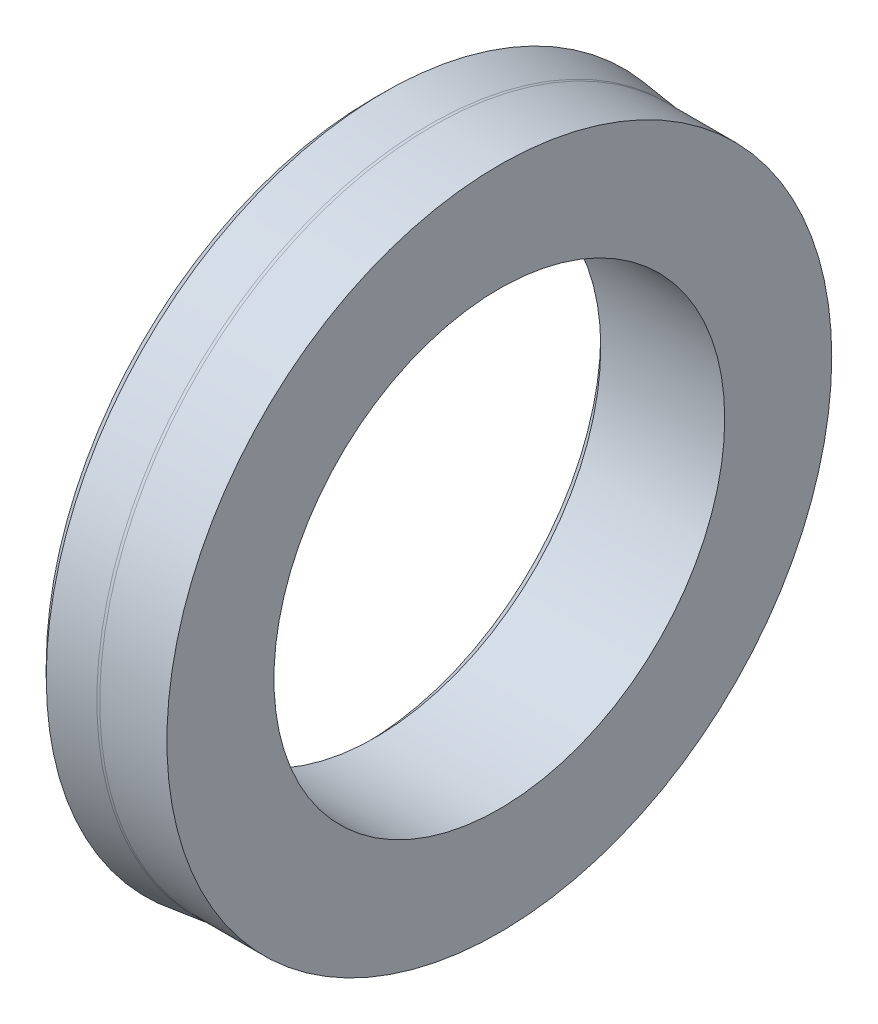
from build123d import *


with BuildPart() as part:
    # Sketch1 → Revolve1 (revolve)
    with BuildSketch(Plane.XY):
        with BuildLine():
            Line((585.92124879, 466.502634686), (596.92124879, 466.502634686))
            Line((596.92124879, 466.502634686), (596.92124879, 475.997634686))
            Line((596.92124879, 475.997634686), (590.964545007, 475.997634686))
            add(Edge.make_bspline(
                [(590.721291168, 476.012482911), (590.802023582, 476.002590232), (590.883208743, 475.997634686), (590.964545007, 475.997634686)],
                knots=[0, 0, 0, 0, 1, 1, 1, 1], degree=3, weights=[1, 0.998761497, 0.998761497, 1]))
            Line((590.721291168, 476.012482911), (586.72124879, 476.502634686))
            Line((586.72124879, 476.502634686), (585.72124879, 475.502634686))
            Line((585.72124879, 475.502634686), (585.72124879, 472.595252763))
            Line((585.72124879, 472.595252763), (589.50305658, 472.131842722))
            add(Edge.make_bspline(
                [(589.50305658, 472.131842722), (590.947204768, 471.954881648), (590.858559549, 470.502634686), (589.403609649, 470.502634686)],
                knots=[0, 0, 0, 0, 1, 1, 1, 1], degree=3, weights=[1, 0.373951098, 0.373951098, 1]))
            Line((589.403609649, 470.502634686), (584.92124879, 470.502634686))
            Line((584.92124879, 470.502634686), (584.92124879, 467.502634686))
            Line((584.92124879, 467.502634686), (585.92124879, 466.502634686))
        make_face()
    revolve(axis=Axis((596.92124879, 446.502634686, 0), (-1, 0, 0)))


solid = part.part
